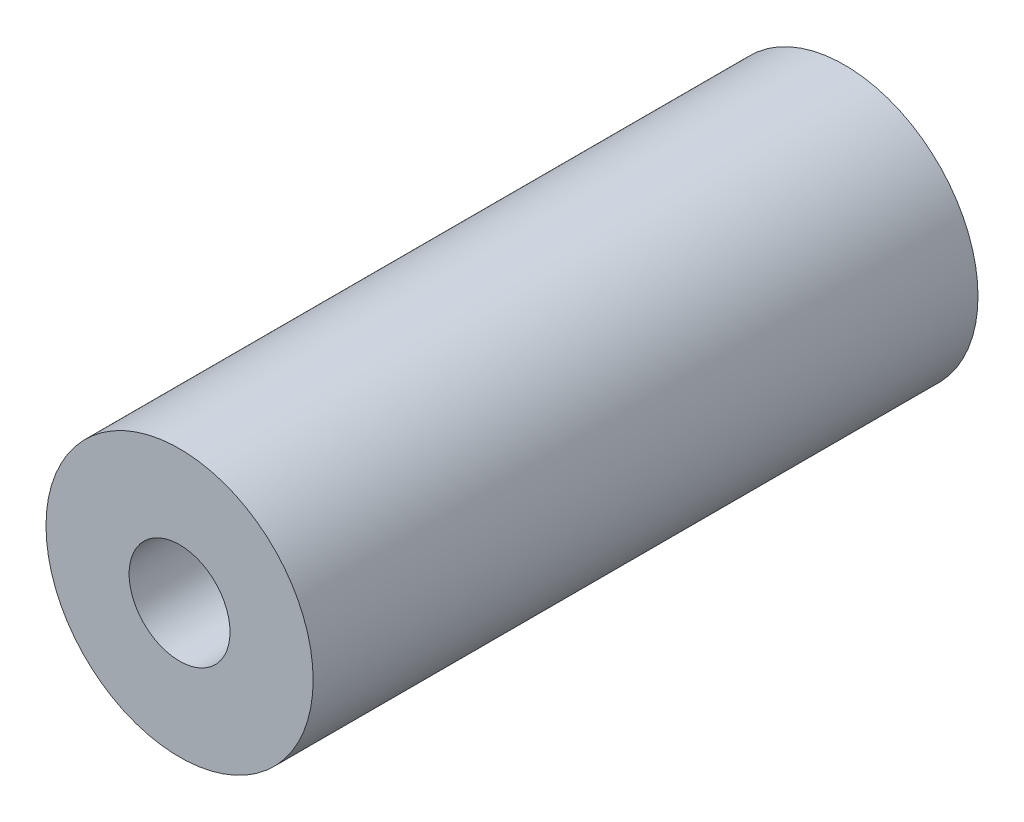
from build123d import *

# Parameters (mm, degrees)
SKETCH1_R           = 30.61716
SKETCH1_R_2         = 11.56716
BOSS_EXTRUDE1_DEPTH = 152.4


with BuildPart() as part:
    # Sketch1 → Boss-Extrude1 (new body)
    with BuildSketch(Plane.XY):
        Circle(SKETCH1_R)
        Circle(SKETCH1_R_2, mode=Mode.SUBTRACT)
    extrude(amount=BOSS_EXTRUDE1_DEPTH)


solid = part.part
